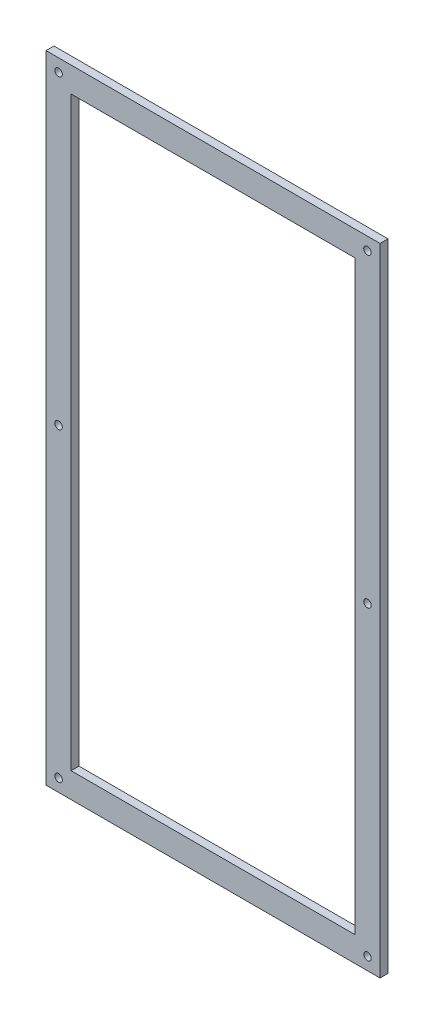
from build123d import *

# Parameters (mm, degrees)
SKETCH1_W           = 133.35
SKETCH1_H           = 254
SKETCH1_R           = 1.5
SKETCH1_W_2         = 113.35
SKETCH1_H_2         = 234
BOSS_EXTRUDE1_DEPTH = 3.175


with BuildPart() as part:
    # Sketch1 → Boss-Extrude1 (new body)
    with BuildSketch(Plane.XY):
        with Locations((66.675, 127)):
            Rectangle(SKETCH1_W, SKETCH1_H)
        with Locations((5, 5)):
            Circle(SKETCH1_R, mode=Mode.SUBTRACT)
        with Locations((5, 249)):
            Circle(SKETCH1_R, mode=Mode.SUBTRACT)
        with Locations((5, 127)):
            Circle(SKETCH1_R, mode=Mode.SUBTRACT)
        with Locations((128.35, 249)):
            Circle(SKETCH1_R, mode=Mode.SUBTRACT)
        with Locations((128.35, 127)):
            Circle(SKETCH1_R, mode=Mode.SUBTRACT)
        with Locations((128.35, 5)):
            Circle(SKETCH1_R, mode=Mode.SUBTRACT)
        with Locations((66.675, 127)):
            Rectangle(SKETCH1_W_2, SKETCH1_H_2, mode=Mode.SUBTRACT)
    extrude(amount=BOSS_EXTRUDE1_DEPTH)


solid = part.part
